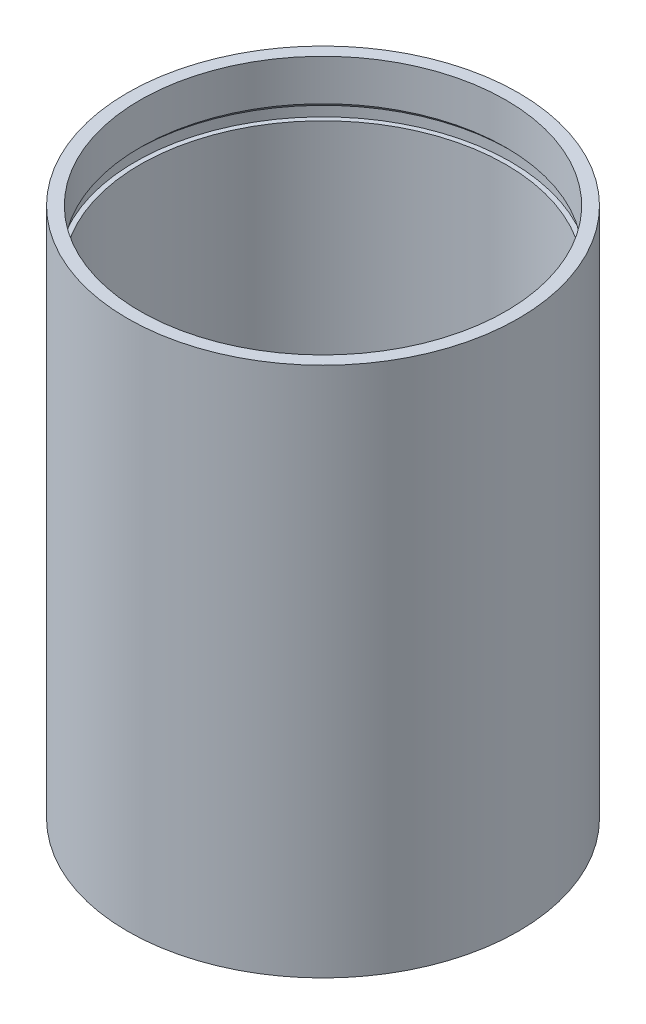
from build123d import *


with BuildPart() as part:
    # Sketch1 → Revolve1 (revolve)
    with BuildSketch(Plane.XY):
        Polygon((-45.85, -52.5), (-45.85, 52.5), (-47.05, 52.5), (-47.05, 55), (-45.85, 56.2), (-45.85, 66.5), (-49, 66.5), (-49, -66.5), (-45.85, -66.5), (-45.85, -56.2), (-47.05, -55), (-47.05, -52.5), align=None)
    revolve(axis=Axis((0, 0, 0), (0, 1, 0)))


solid = part.part
